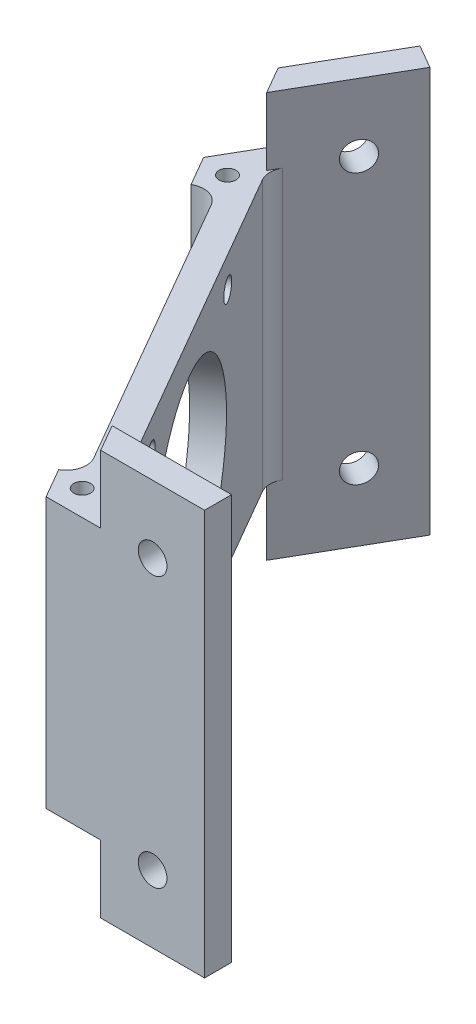
from build123d import *

# Parameters (mm, degrees)
BOSS_EXTRUDE4_DEPTH = 60
CUT_EXTRUDE9_DEPTH  = 10
FILLET5_R           = 3
SKETCH13_R          = 1.25
CUT_EXTRUDE10_DEPTH = 51
SKETCH14_R          = 2.125
CUT_EXTRUDE11_DEPTH = 4
SKETCH15_R          = 2.125
CUT_EXTRUDE12_DEPTH = 4
SKETCH16_R          = 15
SKETCH16_R_2        = 1.6
CUT_EXTRUDE13_DEPTH = 4
CUT_EXTRUDE14_DEPTH = 40


with BuildPart() as part:
    # Sketch1 → Boss-Extrude4 (new body)
    with BuildSketch(Plane(origin=(0, 0, 0), x_dir=(1, 0, 0), z_dir=(0, 1, 0))):
        with BuildLine():
            Line((84.5, 10), (104.5, 10))
            Line((104.5, 10), (104.5, 14))
            Line((104.5, 14), (88.541451884, 14))
            ThreePointArc((88.541451884, 14), (87.041451884, 14.401923789), (85.943375673, 15.5))
            Line((85.943375673, 15.5), (56.395081595, 66.67914662))
            ThreePointArc((56.395081595, 66.67914662), (55.993157806, 68.17914662), (56.395081595, 69.67914662))
            Line((56.395081595, 69.67914662), (64.374355653, 83.499654695))
            Line((64.374355653, 83.499654695), (60.910254038, 85.499654695))
            Line((60.910254038, 85.499654695), (50.910254038, 68.17914662))
            Line((50.910254038, 68.17914662), (46.868804038, 61.179149884))
            Line((46.868804038, 61.179149884), (49.178205115, 57.179149884))
            Line((49.178205115, 57.179149884), (53.219655115, 64.17914662))
            Line((53.219655115, 64.17914662), (82.190598923, 14))
            Line((82.190598923, 14), (74.107698923, 14))
            Line((74.107698923, 14), (76.4171, 10))
            Line((76.4171, 10), (84.5, 10))
        make_face()
    extrude(amount=BOSS_EXTRUDE4_DEPTH)

    # Sketch12 → Cut-Extrude9 (cut)
    with BuildSketch(Plane(origin=(0, 60, 0), x_dir=(1, 0, 0), z_dir=(0, 1, 0))):
        with BuildLine():
            Line((89.118802154, 10), (76.4171, 10))
            Line((76.4171, 10), (46.868804038, 61.179149884))
            Line((46.868804038, 61.179149884), (53.219655115, 72.17914662))
            Line((53.219655115, 72.17914662), (55.529056191, 68.17914662))
            Line((55.529056191, 68.17914662), (56.395081595, 69.67914662))
            ThreePointArc((56.395081595, 69.67914662), (55.993157806, 68.17914662), (56.395081595, 66.67914662))
            Line((56.395081595, 66.67914662), (85.943375673, 15.5))
            ThreePointArc((85.943375673, 15.5), (87.041451884, 14.401923789), (88.541451884, 14))
            Line((88.541451884, 14), (86.809401077, 14))
            Line((86.809401077, 14), (89.118802154, 10))
        make_face()
    cut_extrude9 = extrude(amount=-CUT_EXTRUDE9_DEPTH, mode=Mode.SUBTRACT)

    # Mirror4: Cut-Extrude9 across plane
    add(cut_extrude9.mirror(Plane.ZX.offset(30)), mode=Mode.SUBTRACT)

    # Fillet5
    fillet5_edges = [part.edges().sort_by_distance(p)[0] for p in [
        (82.190598923, 30, -14),
        (53.219655115, 30, -64.17914662),
    ]]
    fillet(fillet5_edges, radius=FILLET5_R)

    # Sketch13 → Cut-Extrude10 (cut, through all)
    with BuildSketch(Plane(origin=(0, 50, 0), x_dir=(1, 0, 0), z_dir=(0, 1, 0))):
        with Locations((53.2197, 64.6791)):
            Circle(SKETCH13_R)
        with Locations((82.6236, 13.75)):
            Circle(SKETCH13_R)
    extrude(amount=-CUT_EXTRUDE10_DEPTH, mode=Mode.SUBTRACT)

    # Sketch14 → Cut-Extrude11 (cut)
    with BuildSketch(Plane.XY.offset(-10)):
        with Locations((96.809401077, 50)):
            Circle(SKETCH14_R)
        with Locations((96.809401077, 10)):
            Circle(SKETCH14_R)
    extrude(amount=-CUT_EXTRUDE11_DEPTH, mode=Mode.SUBTRACT)

    # Sketch15 → Cut-Extrude12 (cut)
    with BuildSketch(Plane(origin=(8.660254038, 0, 5), x_dir=(-0.5, 0, 0.866025404), z_dir=(-0.866025404, 0, -0.5))):
        with Locations((-96.809401077, 50)):
            Circle(SKETCH15_R)
        with Locations((-96.809401077, 10)):
            Circle(SKETCH15_R)
    extrude(amount=-CUT_EXTRUDE12_DEPTH, mode=Mode.SUBTRACT)

    # Sketch16 → Cut-Extrude13 (cut)
    with BuildSketch(Plane(origin=(71.169228634, 0, -41.08957331), x_dir=(-0.5, 0, -0.866025404), z_dir=(0.866025404, 0, -0.5))):
        with Locations((0, 30)):
            Circle(SKETCH16_R)
        with Locations((-15.5, 45.5)):
            Circle(SKETCH16_R_2)
        with Locations((15.5, 45.5)):
            Circle(SKETCH16_R_2)
        with Locations((15.5, 14.5)):
            Circle(SKETCH16_R_2)
        with Locations((-15.5, 14.5)):
            Circle(SKETCH16_R_2)
    extrude(amount=-CUT_EXTRUDE13_DEPTH, mode=Mode.SUBTRACT)

    # Sketch17 → Cut-Extrude14 (cut)
    with BuildSketch(Plane(origin=(0, 50, 0), x_dir=(1, 0, 0), z_dir=(0, 1, 0))):
        Polygon((46.868804038, 61.179149884), (76.4171, 10), (81.0358, 10), (49.178154038, 65.179061416), align=None)
    extrude(amount=-CUT_EXTRUDE14_DEPTH, mode=Mode.SUBTRACT)


solid = part.part
